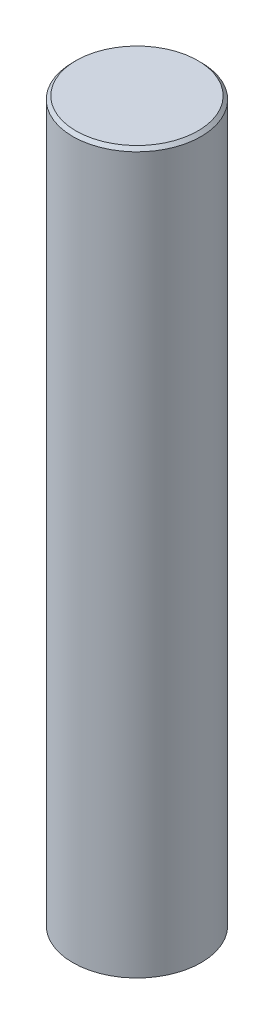
from build123d import *

# Parameters (mm, degrees)
SKETCH1_R           = 20
BOSS_EXTRUDE1_DEPTH = 224
CHAMFER2_SIZE       = 1


with BuildPart() as part:
    # Sketch1 → Boss-Extrude1 (new body)
    with BuildSketch(Plane(origin=(0, 0, 0), x_dir=(1, 0, 0), z_dir=(0, 1, 0))):
        Circle(SKETCH1_R)
    extrude(amount=BOSS_EXTRUDE1_DEPTH)

    # Chamfer2
    chamfer2_edges = [part.edges().sort_by_distance(p)[0] for p in [
        (-20, 224, 0),
    ]]
    chamfer(chamfer2_edges, length=CHAMFER2_SIZE)


solid = part.part
